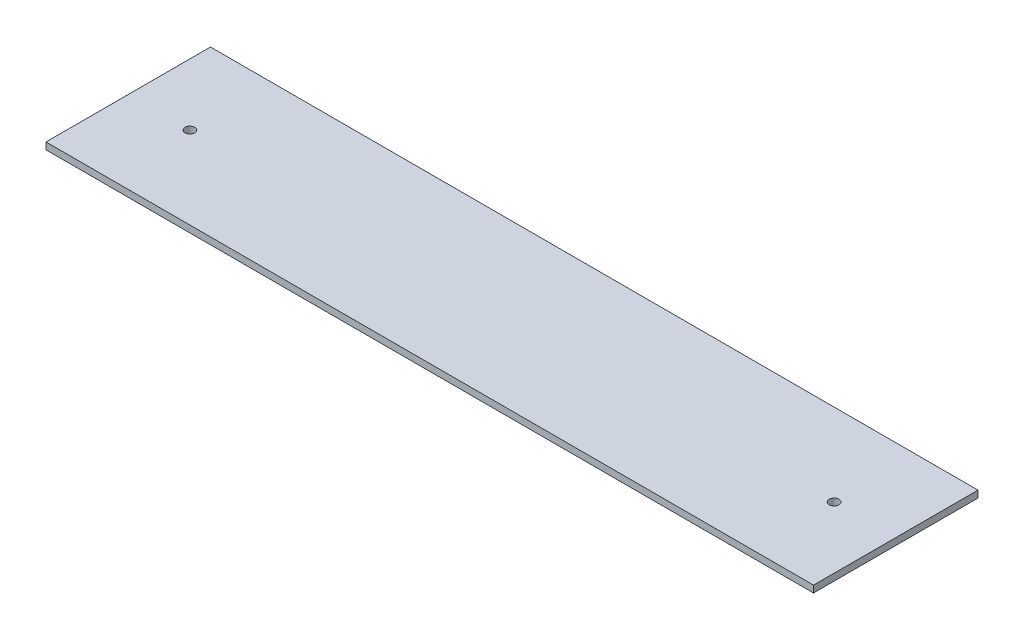
from build123d import *

# Parameters (mm, degrees)
SKETCH1_W           = 355.6
SKETCH1_H           = 76.2
SKETCH1_R           = 2.25
BOSS_EXTRUDE1_DEPTH = 3.175


with BuildPart() as part:
    # Sketch1 → Boss-Extrude1 (new body)
    with BuildSketch(Plane(origin=(0, 0, 0), x_dir=(1, 0, 0), z_dir=(0, 1, 0))):
        Rectangle(SKETCH1_W, SKETCH1_H)
        with Locations((-149.225, 0)):
            Circle(SKETCH1_R, mode=Mode.SUBTRACT)
        with Locations((149.225, 0)):
            Circle(SKETCH1_R, mode=Mode.SUBTRACT)
    extrude(amount=-BOSS_EXTRUDE1_DEPTH)


solid = part.part
